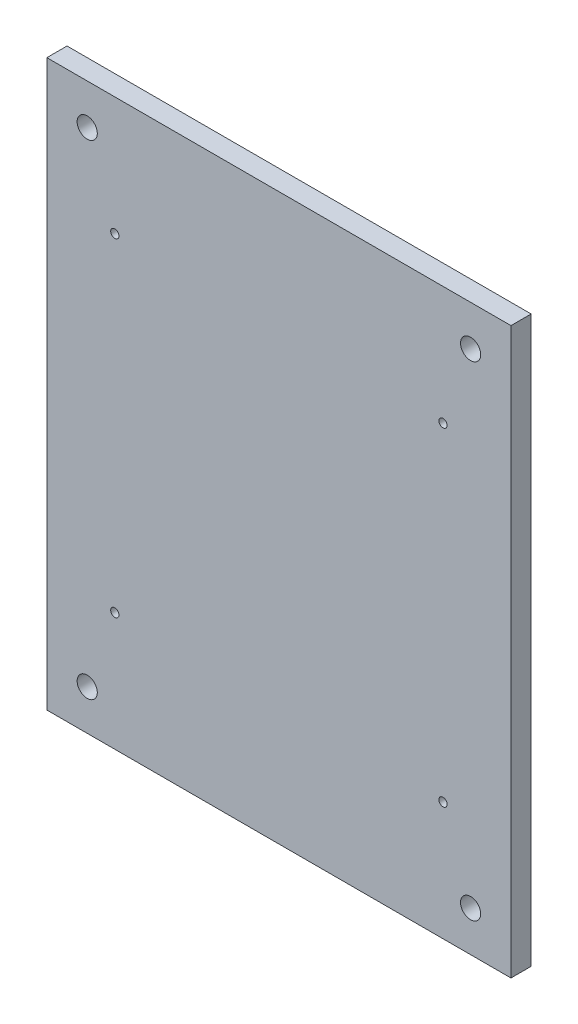
from build123d import *

# Parameters (mm, degrees)
SKETCH1_R           = 1.025
BOSS_EXTRUDE1_DEPTH = 5
SKETCH2_W           = 115
SKETCH2_H           = 140
SKETCH2_R           = 2.5
BOSS_EXTRUDE2_DEPTH = 5
CUT_EXTRUDE1_START  = -10
SKETCH3_R           = 1.025
CUT_EXTRUDE1_DEPTH  = 5


with BuildPart() as part:
    # Sketch1 → Boss-Extrude1 (new body)
    with BuildSketch(Plane.XY):
        with BuildLine():
            Line((4, 0), (90.5, 0))
            ThreePointArc((90.5, 0), (93.328427125, 1.171572875), (94.5, 4))
            Line((94.5, 4), (94.5, 90.5))
            ThreePointArc((94.5, 90.5), (93.328427125, 93.328427125), (90.5, 94.5))
            Line((90.5, 94.5), (4, 94.5))
            ThreePointArc((4, 94.5), (1.171572875, 93.328427125), (0, 90.5))
            Line((0, 90.5), (0, 4))
            ThreePointArc((0, 4), (1.171572875, 1.171572875), (4, 0))
        make_face()
        with Locations((6.59, 87.91)):
            Circle(SKETCH1_R, mode=Mode.SUBTRACT)
        with Locations((87.91, 87.91)):
            Circle(SKETCH1_R, mode=Mode.SUBTRACT)
        with Locations((6.59, 6.59)):
            Circle(SKETCH1_R, mode=Mode.SUBTRACT)
        with Locations((87.91, 6.59)):
            Circle(SKETCH1_R, mode=Mode.SUBTRACT)
    extrude(amount=BOSS_EXTRUDE1_DEPTH)

    # Sketch2 → Boss-Extrude2 (add)
    with BuildSketch(Plane.XY.offset(5)):
        with Locations((47.25, 47.25)):
            Rectangle(SKETCH2_W, SKETCH2_H)
        with Locations((94.75, 107.25)):
            Circle(SKETCH2_R, mode=Mode.SUBTRACT)
        with Locations((94.75, -12.75)):
            Circle(SKETCH2_R, mode=Mode.SUBTRACT)
        with Locations((-0.25, 107.25)):
            Circle(SKETCH2_R, mode=Mode.SUBTRACT)
        with Locations((-0.25, -12.75)):
            Circle(SKETCH2_R, mode=Mode.SUBTRACT)
    extrude(amount=BOSS_EXTRUDE2_DEPTH)

    # Sketch3 → Cut-Extrude1 (cut)
    with BuildSketch(Plane(origin=(0, 0, 0), x_dir=(-1, 0, 0), z_dir=(0, 0, -1)).offset(CUT_EXTRUDE1_START)):
        with Locations((-87.91, 6.59)):
            Circle(SKETCH3_R)
        with Locations((-6.59, 6.59)):
            Circle(SKETCH3_R)
        with Locations((-6.59, 87.91)):
            Circle(SKETCH3_R)
        with Locations((-87.91, 87.91)):
            Circle(SKETCH3_R)
    extrude(amount=CUT_EXTRUDE1_DEPTH, mode=Mode.SUBTRACT)


solid = part.part
